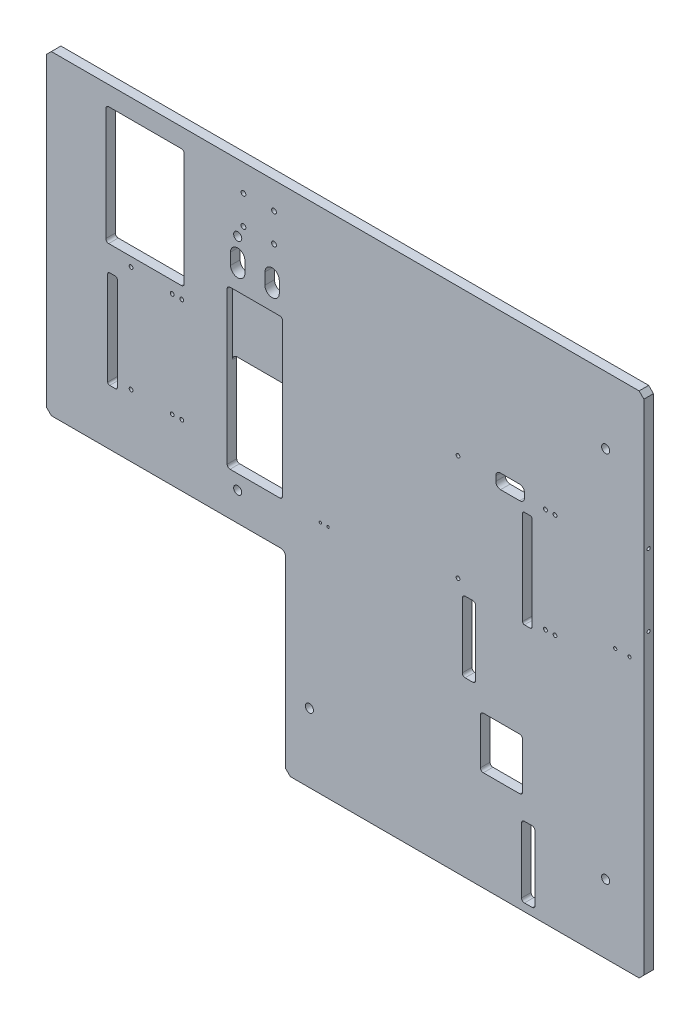
from build123d import *

# Parameters (mm, degrees)
SKETCH1_W             = 82
SKETCH1_H             = 124
SKETCH1_W_2           = 44
SKETCH1_H_2           = 54
SKETCH1_W_3           = 10
SKETCH1_H_3           = 102
SKETCH1_W_4           = 14
SKETCH1_H_4           = 74
SKETCH1_W_5           = 30
SKETCH1_H_5           = 15
BOSS_EXTRUDE1_DEPTH   = 10
FILLET1_R             = 3
FILLET2_R             = 2
FILLET3_R             = 5
FILLET4_R             = 2
FILLET5_R             = 3
CHAMFER1_SIZE         = 5
FILLET6_R             = 5
SKETCH2_W             = 58
SKETCH2_H             = 165
CUT_EXTRUDE1_DEPTH    = 5.5
SKETCH3_W             = 58
SKETCH3_H             = 100
CUT_EXTRUDE2_DEPTH    = 5.5
FILLET7_R             = 3
FILLET8_R             = 5
SKETCH4_R             = 2
CUT_EXTRUDE3_DEPTH    = 11
M4_TAPPED_HOLE1_D     = 3.3
M4_TAPPED_HOLE1_DEPTH = 8
M4_TAPPED_HOLE1_TIP   = 0.991420021
M4_TAPPED_HOLE2_D     = 3.3
M4_TAPPED_HOLE2_DEPTH = 8
M4_TAPPED_HOLE2_TIP   = 0.991420021
M10_TAPPED_HOLE1_D    = 8.5
M4_TAPPED_HOLE3_D     = 3.3
M4_TAPPED_HOLE3_DEPTH = 10.1
M4_TAPPED_HOLE3_TIP   = 0.991420021
SKETCH15_R            = 2
CUT_EXTRUDE4_DEPTH    = 11
M3_TAPPED_HOLE1_D     = 2.5
M3_TAPPED_HOLE1_DEPTH = 7.5
M3_TAPPED_HOLE1_TIP   = 0.751075774
M6_TAPPED_HOLE1_D     = 5
M6_TAPPED_HOLE1_DEPTH = 15
M6_TAPPED_HOLE1_TIP   = 1.502151548


with BuildPart() as part:
    # Sketch1 → Boss-Extrude1 (new body)
    with BuildSketch(Plane.XY):
        Polygon((-81.731872987, 190.622065728), (543.268127013, 190.622065728), (543.268127013, -341.377934272), (168.268127013, -341.377934272), (168.268127013, -139.377934272), (-81.731872987, -139.377934272), align=None)
        with Locations((21.268127013, 108.622065728)):
            Rectangle(SKETCH1_W, SKETCH1_H, mode=Mode.SUBTRACT)
        with Locations((394.268127013, -209.877934272)):
            Rectangle(SKETCH1_W_2, SKETCH1_H_2, mode=Mode.SUBTRACT)
        with Locations((-12.731872987, -30.377934272)):
            Rectangle(SKETCH1_W_3, SKETCH1_H_3, mode=Mode.SUBTRACT)
        with BuildLine():
            Line((110.768127013, 102.622065728), (110.768127013, 90.622065728))
            ThreePointArc((110.768127013, 90.622065728), (118.268127013, 83.122065728), (125.768127013, 90.622065728))
            Line((125.768127013, 90.622065728), (125.768127013, 102.622065728))
            ThreePointArc((125.768127013, 102.622065728), (118.268127013, 110.122065728), (110.768127013, 102.622065728))
        make_face(mode=Mode.SUBTRACT)
        with BuildLine():
            Line((146.768127013, 102.622065728), (146.768127013, 90.622065728))
            ThreePointArc((146.768127013, 90.622065728), (154.268127013, 83.122065728), (161.768127013, 90.622065728))
            Line((161.768127013, 90.622065728), (161.768127013, 102.622065728))
            ThreePointArc((161.768127013, 102.622065728), (154.268127013, 110.122065728), (146.768127013, 102.622065728))
        make_face(mode=Mode.SUBTRACT)
        with Locations((360.268127013, -123.377934272)):
            Rectangle(SKETCH1_W_4, SKETCH1_H_4, mode=Mode.SUBTRACT)
        with Locations((422.268127013, -296.377934272)):
            Rectangle(SKETCH1_W_4, SKETCH1_H_4, mode=Mode.SUBTRACT)
        with Locations((403.268127013, 36.122065728)):
            Rectangle(SKETCH1_W_5, SKETCH1_H_5, mode=Mode.SUBTRACT)
        with Locations((421.268127013, -30.377934272)):
            Rectangle(SKETCH1_W_3, SKETCH1_H_3, mode=Mode.SUBTRACT)
    extrude(amount=BOSS_EXTRUDE1_DEPTH)

    # Fillet1
    fillet1_edges = [part.edges().sort_by_distance(p)[0] for p in [
        (-19.731872987, 170.622065728, 5),
        (-19.731872987, 46.622065728, 5),
        (62.268127013, 46.622065728, 5),
        (62.268127013, 170.622065728, 5),
    ]]
    fillet(fillet1_edges, radius=FILLET1_R)

    # Fillet2
    fillet2_edges = [part.edges().sort_by_distance(p)[0] for p in [
        (-17.731872987, 20.622065728, 5),
        (-17.731872987, -81.377934272, 5),
        (-7.731872987, -81.377934272, 5),
        (-7.731872987, 20.622065728, 5),
    ]]
    fillet(fillet2_edges, radius=FILLET2_R)

    # Fillet3
    fillet3_edges = [part.edges().sort_by_distance(p)[0] for p in [
        (388.268127013, 43.622065728, 5),
        (388.268127013, 28.622065728, 5),
        (418.268127013, 28.622065728, 5),
        (418.268127013, 43.622065728, 5),
    ]]
    fillet(fillet3_edges, radius=FILLET3_R)

    # Fillet4
    fillet4_edges = [part.edges().sort_by_distance(p)[0] for p in [
        (416.268127013, 20.622065728, 5),
        (416.268127013, -81.377934272, 5),
        (426.268127013, -81.377934272, 5),
        (426.268127013, 20.622065728, 5),
    ]]
    fillet(fillet4_edges, radius=FILLET4_R)

    # Fillet5
    fillet5_edges = [part.edges().sort_by_distance(p)[0] for p in [
        (372.268127013, -182.877934272, 5),
        (372.268127013, -236.877934272, 5),
        (416.268127013, -236.877934272, 5),
        (416.268127013, -182.877934272, 5),
        (415.268127013, -259.377934272, 5),
        (415.268127013, -333.377934272, 5),
        (429.268127013, -333.377934272, 5),
        (429.268127013, -259.377934272, 5),
        (353.268127013, -86.377934272, 5),
        (353.268127013, -160.377934272, 5),
        (367.268127013, -160.377934272, 5),
        (367.268127013, -86.377934272, 5),
    ]]
    fillet(fillet5_edges, radius=FILLET5_R)

    # Chamfer1
    chamfer1_edges = [part.edges().sort_by_distance(p)[0] for p in [
        (-81.731872987, 190.622065728, 5),
        (543.268127013, 190.622065728, 5),
        (543.268127013, -341.377934272, 5),
        (168.268127013, -341.377934272, 5),
        (-81.731872987, -139.377934272, 5),
    ]]
    chamfer(chamfer1_edges, length=CHAMFER1_SIZE)

    # Fillet6
    fillet6_edges = [part.edges().sort_by_distance(p)[0] for p in [
        (168.268127013, -139.377934272, 5),
    ]]
    fillet(fillet6_edges, radius=FILLET6_R)

    # Sketch2 → Cut-Extrude1 (cut)
    with BuildSketch(Plane.XY.offset(10)):
        with Locations((136.268127013, -11.877934272)):
            Rectangle(SKETCH2_W, SKETCH2_H)
    extrude(amount=-CUT_EXTRUDE1_DEPTH, mode=Mode.SUBTRACT)

    # Sketch3 → Cut-Extrude2 (cut, through all)
    with BuildSketch(Plane.XY.offset(4.5)):
        with Locations((136.268127013, -44.377934272)):
            Rectangle(SKETCH3_W, SKETCH3_H)
    extrude(amount=-CUT_EXTRUDE2_DEPTH, mode=Mode.SUBTRACT)

    # Fillet7
    fillet7_edges = [part.edges().sort_by_distance(p)[0] for p in [
        (107.268127013, -94.377934272, 5),
        (107.268127013, 70.622065728, 7.25),
        (165.268127013, 70.622065728, 7.25),
        (165.268127013, -94.377934272, 5),
    ]]
    fillet(fillet7_edges, radius=FILLET7_R)

    # Fillet8
    fillet8_edges = [part.edges().sort_by_distance(p)[0] for p in [
        (165.268127013, 5.622065728, 2.25),
        (107.268127013, 5.622065728, 2.25),
    ]]
    fillet(fillet8_edges, radius=FILLET8_R)

    # Sketch4 → Cut-Extrude3 (cut, through all)
    with BuildSketch(Plane.XY.offset(10)):
        with Locations((6.768127013, 37.122065728)):
            Circle(SKETCH4_R)
        with Locations((6.768127013, -73.877934272)):
            Circle(SKETCH4_R)
        with Locations((348.768127013, 37.122065728)):
            Circle(SKETCH4_R)
        with Locations((348.768127013, -73.877934272)):
            Circle(SKETCH4_R)
    extrude(amount=-CUT_EXTRUDE3_DEPTH, mode=Mode.SUBTRACT)

    # M4 Tapped Hole1
    with Locations(Plane.ZY.offset(81.731872987)):
        with Locations((5, 47.622065728), (5, -27.377934272)):
            Hole(M4_TAPPED_HOLE1_D / 2, depth=M4_TAPPED_HOLE1_DEPTH)
            with Locations((0, 0, -(M4_TAPPED_HOLE1_DEPTH + M4_TAPPED_HOLE1_TIP / 2))):  # 118° drill point
                Cone(0, M4_TAPPED_HOLE1_D / 2, M4_TAPPED_HOLE1_TIP, mode=Mode.SUBTRACT)

    # M4 Tapped Hole2
    with Locations(Plane(origin=(543.268127013, 0, 0), x_dir=(0, 0, -1), z_dir=(1, 0, 0))):
        with Locations((-5, 47.622065728), (-5, -27.377934272)):
            Hole(M4_TAPPED_HOLE2_D / 2, depth=M4_TAPPED_HOLE2_DEPTH)
            with Locations((0, 0, -(M4_TAPPED_HOLE2_DEPTH + M4_TAPPED_HOLE2_TIP / 2))):  # 118° drill point
                Cone(0, M4_TAPPED_HOLE2_D / 2, M4_TAPPED_HOLE2_TIP, mode=Mode.SUBTRACT)

    # M10 Tapped Hole1 (through all)
    with Locations(Plane.XY.offset(10)):
        with Locations((118.268127013, -109.377934272), (193.268127013, -269.377934272), (503.268127013, -269.377934272), (118.268127013, 120.622065728), (503.268127013, 120.622065728)):
            Hole(M10_TAPPED_HOLE1_D / 2)

    # M4 Tapped Hole3
    with Locations(Plane.XY.offset(10)):
        with Locations((513.268127013, -55.377934272), (528.268127013, -55.377934272)):
            Hole(M4_TAPPED_HOLE3_D / 2, depth=M4_TAPPED_HOLE3_DEPTH)
            with Locations((0, 0, -(M4_TAPPED_HOLE3_DEPTH + M4_TAPPED_HOLE3_TIP / 2))):  # 118° drill point
                Cone(0, M4_TAPPED_HOLE3_D / 2, M4_TAPPED_HOLE3_TIP, mode=Mode.SUBTRACT)

    # Sketch15 → Cut-Extrude4 (cut, through all)
    with BuildSketch(Plane.XY.offset(10)):
        with Locations((49.768127013, 34.222065728)):
            Circle(SKETCH15_R)
        with Locations((49.768127013, -74.777934272)):
            Circle(SKETCH15_R)
        with Locations((440.268127013, 34.222065728)):
            Circle(SKETCH15_R)
        with Locations((440.268127013, -74.777934272)):
            Circle(SKETCH15_R)
        with Locations((59.768127013, 34.222065728)):
            Circle(SKETCH15_R)
        with Locations((59.768127013, -74.777934272)):
            Circle(SKETCH15_R)
        with Locations((450.268127013, 34.222065728)):
            Circle(SKETCH15_R)
        with Locations((450.268127013, -74.777934272)):
            Circle(SKETCH15_R)
    extrude(amount=-CUT_EXTRUDE4_DEPTH, mode=Mode.SUBTRACT)

    # M3 Tapped Hole1
    with Locations(Plane.XY.offset(10)):
        with Locations((204.768127013, -95.377934272), (212.768127013, -95.377934272)):
            Hole(M3_TAPPED_HOLE1_D / 2, depth=M3_TAPPED_HOLE1_DEPTH)
            with Locations((0, 0, -(M3_TAPPED_HOLE1_DEPTH + M3_TAPPED_HOLE1_TIP / 2))):  # 118° drill point
                Cone(0, M3_TAPPED_HOLE1_D / 2, M3_TAPPED_HOLE1_TIP, mode=Mode.SUBTRACT)

    # M6 Tapped Hole1
    with Locations(Plane.XY.offset(10)):
        with Locations((124.268127013, 162.622065728), (156.268127013, 162.622065728), (124.268127013, 132.622065728), (156.268127013, 132.622065728)):
            Hole(M6_TAPPED_HOLE1_D / 2, depth=M6_TAPPED_HOLE1_DEPTH)
            with Locations((0, 0, -(M6_TAPPED_HOLE1_DEPTH + M6_TAPPED_HOLE1_TIP / 2))):  # 118° drill point
                Cone(0, M6_TAPPED_HOLE1_D / 2, M6_TAPPED_HOLE1_TIP, mode=Mode.SUBTRACT)


solid = part.part
